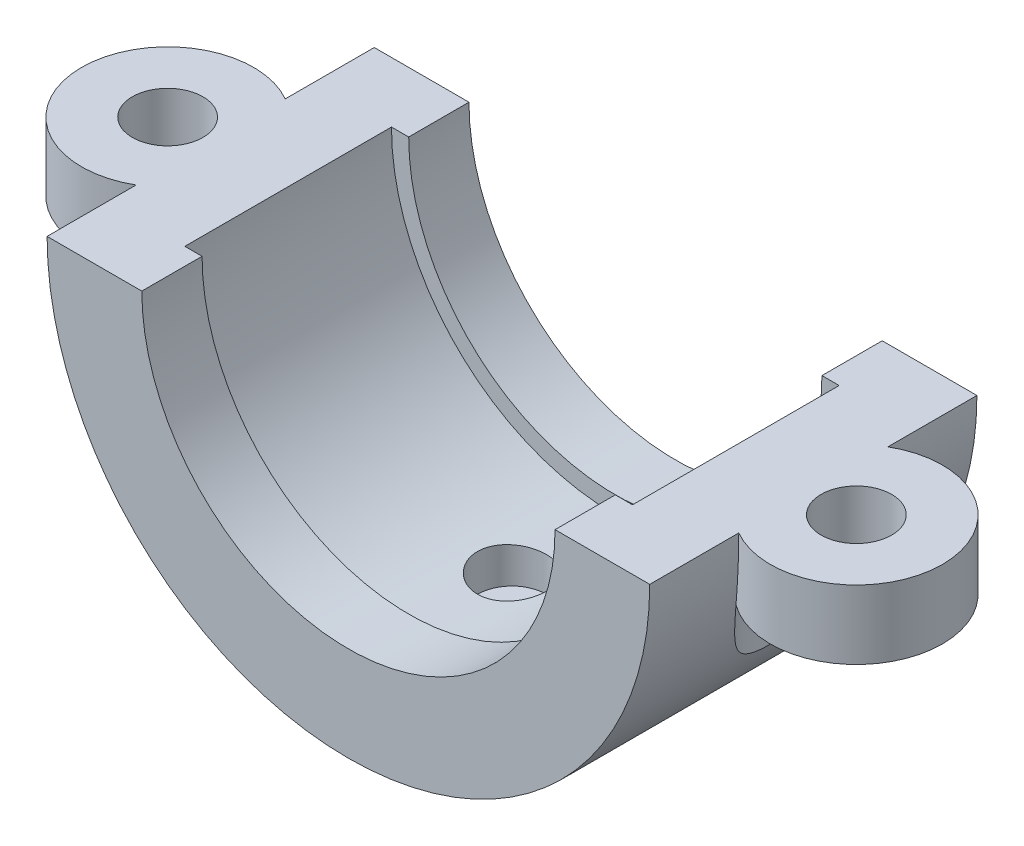
from build123d import *

# Parameters (mm, degrees)
EXTRUDE_2_DEPTH     = 19
SKETCH_2_R          = 10
EXTRUDE_3_DEPTH     = 40
SKETCH_3_R          = 10
CUT_EXTRUDE_1_DEPTH = 32
SKETCH_4_R          = 4.1
CUT_EXTRUDE_2_DEPTH = 9.0000001
EXTRUDE_START       = -37
SKETCH_5_R          = 10
SKETCH_5_R_2        = 1.5
EXTRUDE_4_DEPTH     = 3.45898
SKETCH_5_4_R        = 1.5
CUT_EXTRUDE_3_DEPTH = 38.0000001
CUT_EXTRUDE_4_DEPTH = 12
SKETCH_6_R          = 4
CUT_EXTRUDE_5_DEPTH = 30


with BuildPart() as part:
    # Эскиз1 → Бобышка-Вытянуть2 (new body, symmetric)
    with BuildSketch(Plane.XY):
        with BuildLine():
            Line((35, 0), (26, 0))
            ThreePointArc((26, 0), (0, -26), (-26, 0))
            Line((-26, 0), (-35, 0))
            ThreePointArc((-35, 0), (0, -35), (35, 0))
        make_face()
        with BuildLine():
            Line((26, 0), (24, 0))
            ThreePointArc((24, 0), (0, -24), (-24, 0))
            Line((-24, 0), (-26, 0))
            ThreePointArc((-26, 0), (0, -26), (26, 0))
        make_face()
    extrude(amount=EXTRUDE_2_DEPTH, both=True)

    # Эскиз2 → Бобышка-Вытянуть3 (add)
    with BuildSketch(Plane(origin=(0, 0, 0), x_dir=(1, 0, 0), z_dir=(0, 1, 0))):
        with Locations((40, 0)):
            Circle(SKETCH_2_R)
    extrude_3 = extrude(amount=-EXTRUDE_3_DEPTH)

    # Эскиз3 → Вырез-Вытянуть1 (cut)
    with BuildSketch(Plane.XZ.offset(40)):
        with Locations((40, 0)):
            Circle(SKETCH_3_R)
    cut_extrude_1 = extrude(amount=-CUT_EXTRUDE_1_DEPTH, mode=Mode.SUBTRACT)

    # Эскиз4 → Вырез-Вытянуть2 (cut, through all)
    with BuildSketch(Plane.XZ.offset(8)):
        with Locations((40, 0)):
            Circle(SKETCH_4_R)
    cut_extrude_2 = extrude(amount=-CUT_EXTRUDE_2_DEPTH, mode=Mode.SUBTRACT)

    # Зеркальное отражение1: Бобышка-Вытянуть3, Вырез-Вытянуть1, Вырез-Вытянуть2 across plane
    add(extrude_3.mirror(Plane(origin=(0, 0, 0), x_dir=(0, 0, 1), z_dir=(1, 0, 0))))
    add(cut_extrude_1.mirror(Plane(origin=(0, 0, 0), x_dir=(0, 0, 1), z_dir=(1, 0, 0))), mode=Mode.SUBTRACT)
    add(cut_extrude_2.mirror(Plane(origin=(0, 0, 0), x_dir=(0, 0, 1), z_dir=(1, 0, 0))), mode=Mode.SUBTRACT)

    # Эскиз5 → Бобышка-Вытянуть4 (add)
    with BuildSketch(Plane(origin=(0, 0, 0), x_dir=(1, 0, 0), z_dir=(0, 1, 0)).offset(EXTRUDE_START)):
        Circle(SKETCH_5_R)
        Circle(SKETCH_5_R_2, mode=Mode.SUBTRACT)
        Circle(SKETCH_5_R_2)
    extrude(amount=EXTRUDE_4_DEPTH)

    # Эскиз5<4> → Вырез-Вытянуть3 (cut, through all)
    with BuildSketch(Plane(origin=(0, 0, 0), x_dir=(1, 0, 0), z_dir=(0, 1, 0))):
        Circle(SKETCH_5_4_R)
    extrude(amount=-CUT_EXTRUDE_3_DEPTH, mode=Mode.SUBTRACT)

    # Эскиз1<4> → Вырез-Вытянуть4 (cut, symmetric)
    with BuildSketch(Plane.XY):
        with BuildLine():
            ThreePointArc((-24, 0), (0, 24), (24, 0))
            Line((24, 0), (26, 0))
            ThreePointArc((26, 0), (0, 26), (-26, 0))
            Line((-26, 0), (-24, 0))
        make_face()
        with BuildLine():
            Line((26, 0), (24, 0))
            ThreePointArc((24, 0), (0, -24), (-24, 0))
            Line((-24, 0), (-26, 0))
            ThreePointArc((-26, 0), (0, -26), (26, 0))
        make_face()
    extrude(amount=CUT_EXTRUDE_4_DEPTH, both=True, mode=Mode.SUBTRACT)

    # Эскиз6 → Вырез-Вытянуть5 (cut)
    with BuildSketch(Plane(origin=(0, 0, 0), x_dir=(1, 0, 0), z_dir=(0, 1, 0))):
        Circle(SKETCH_6_R)
    extrude(amount=-CUT_EXTRUDE_5_DEPTH, mode=Mode.SUBTRACT)


solid = part.part
